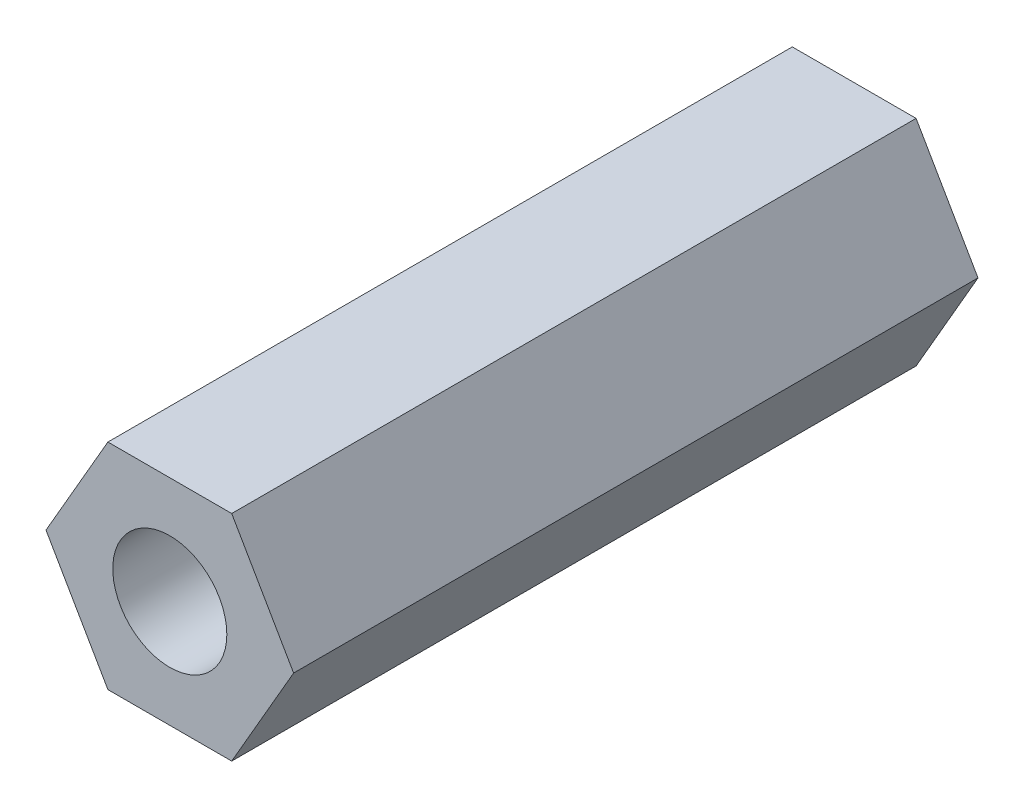
from build123d import *

# Parameters (mm, degrees)
EXTRUDE_1_DEPTH = 7.5


with BuildPart() as part:
    # 草图1 → 凸台-拉伸1 (new body, symmetric)
    with BuildSketch(Plane.XY):
        Polygon((1.356773133, 2.35), (-1.356773133, 2.35), (-2.713546265, 0), (-1.356773133, -2.35), (1.356773133, -2.35), (2.713546265, 0), align=None)
    extrude(amount=EXTRUDE_1_DEPTH, both=True)

    # 草图3 → Hole Wizard 387 (revolve, cut)
    with BuildSketch(Plane(origin=(0, 0, 7.5), x_dir=(0, -1, 0), z_dir=(1, 0, 0))):
        Polygon((0, 0), (0, 8.751075774), (1.25, 8), (1.25, 0), align=None)
    hole_wizard_387 = revolve(axis=Axis((0, 0, 13.85), (0, 0, -1)), mode=Mode.SUBTRACT)

    # 镜向1: Hole Wizard 387 across plane
    add(hole_wizard_387.mirror(Plane.XY), mode=Mode.SUBTRACT)


solid = part.part
